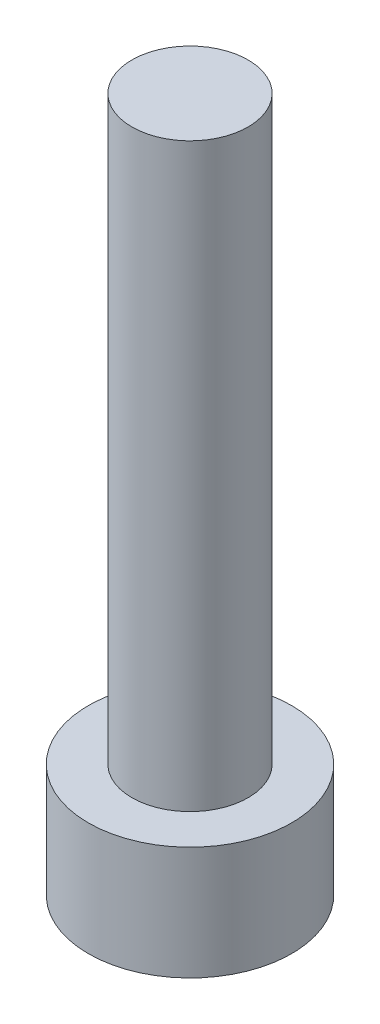
from build123d import *

# Parameters (mm, degrees)
SKETCH_1_R          = 3.5
EXTRUDE_1_DEPTH     = 3.9
SKETCH_2_R          = 2
EXTRUDE_2_DEPTH     = 20
CUT_EXTRUDE_1_DEPTH = 2.4


with BuildPart() as part:
    # 草图1 → 凸台-拉伸1 (new body)
    with BuildSketch(Plane(origin=(0, 0, 0), x_dir=(1, 0, 0), z_dir=(0, 1, 0))):
        Circle(SKETCH_1_R)
    extrude(amount=EXTRUDE_1_DEPTH)

    # 草图2 → 凸台-拉伸2 (add)
    with BuildSketch(Plane(origin=(0, 3.9, 0), x_dir=(1, 0, 0), z_dir=(0, 1, 0))):
        Circle(SKETCH_2_R)
    extrude(amount=EXTRUDE_2_DEPTH)

    # 草图3 → 切除-拉伸1 (cut)
    with BuildSketch(Plane.XZ):
        Polygon((1.725, 0), (0.8625, 1.493893822), (-0.8625, 1.493893822), (-1.725, 0), (-0.8625, -1.493893822), (0.8625, -1.493893822), align=None)
    extrude(amount=-CUT_EXTRUDE_1_DEPTH, mode=Mode.SUBTRACT)


solid = part.part
